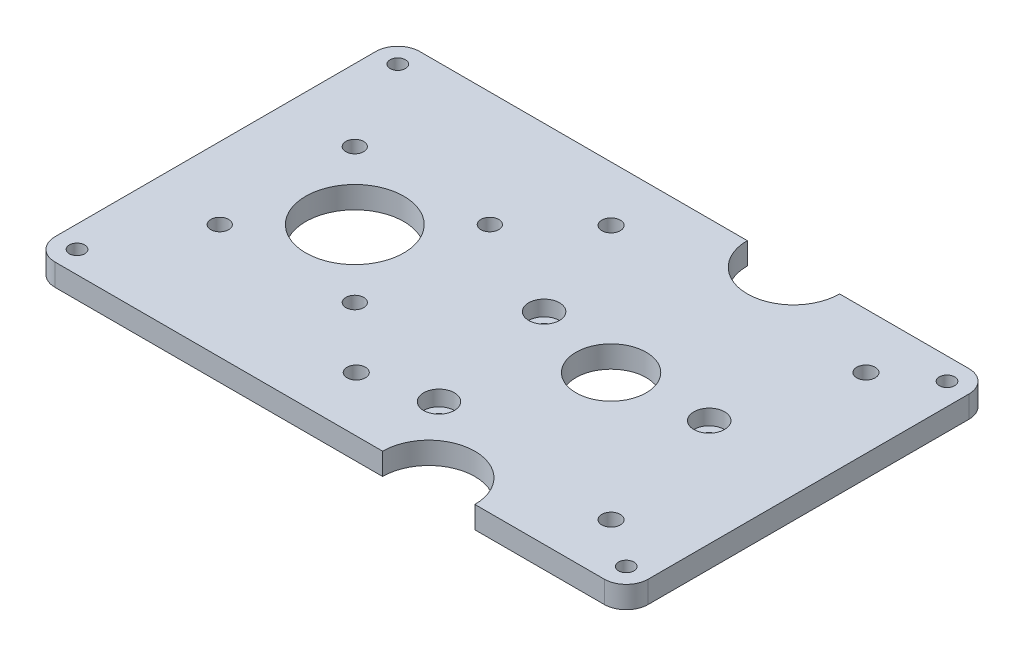
from build123d import *

# Parameters (mm, degrees)
SKETCH1_R           = 2.1
SKETCH1_R_2         = 8
SKETCH1_R_3         = 11.176
SKETCH1_R_4         = 1.75
SKETCH1_R_5         = 2.032
BOSS_EXTRUDE1_DEPTH = 5
FILLET1_R           = 5
SKETCH8_R           = 1.65
CUT_EXTRUDE3_DEPTH  = 10
SKETCH9_R           = 3.5
SKETCH9_R_2         = 1.65
CUT_EXTRUDE4_DEPTH  = 3.5


with BuildPart() as part:
    # Sketch1 → Boss-Extrude1 (new body)
    with BuildSketch(Plane(origin=(0, 0, 0), x_dir=(1, 0, 0), z_dir=(0, 1, 0))):
        with BuildLine():
            Line((67.5, -41.5), (33.05, -41.5))
            ThreePointArc((33.05, -41.5), (22.55, -31), (12.05, -41.5))
            Line((12.05, -41.5), (-67.5, -41.5))
            Line((-67.5, -41.5), (-67.5, 41.5))
            Line((-67.5, 41.5), (12.05, 41.5))
            ThreePointArc((12.05, 41.5), (22.55, 31), (33.05, 41.5))
            Line((33.05, 41.5), (67.5, 41.5))
            Line((67.5, 41.5), (67.5, -41.5))
        make_face()
        with Locations((-6.45, 29)):
            Circle(SKETCH1_R, mode=Mode.SUBTRACT)
        with Locations((51.55, 29)):
            Circle(SKETCH1_R, mode=Mode.SUBTRACT)
        with Locations((51.55, -29)):
            Circle(SKETCH1_R, mode=Mode.SUBTRACT)
        with Locations((-6.45, -29)):
            Circle(SKETCH1_R, mode=Mode.SUBTRACT)
        with Locations((22.55, 0)):
            Circle(SKETCH1_R_2, mode=Mode.SUBTRACT)
        with Locations((-35.78, 0)):
            Circle(SKETCH1_R_3, mode=Mode.SUBTRACT)
        with Locations((-62.5, 36.5)):
            Circle(SKETCH1_R_4, mode=Mode.SUBTRACT)
        with Locations((62.5, 36.5)):
            Circle(SKETCH1_R_4, mode=Mode.SUBTRACT)
        with Locations((62.5, -36.5)):
            Circle(SKETCH1_R_4, mode=Mode.SUBTRACT)
        with Locations((-62.5, -36.5)):
            Circle(SKETCH1_R_4, mode=Mode.SUBTRACT)
        with Locations((-20.413, 15.367)):
            Circle(SKETCH1_R_5, mode=Mode.SUBTRACT)
        with Locations((-20.413, -15.367)):
            Circle(SKETCH1_R_5, mode=Mode.SUBTRACT)
        with Locations((-51.147, -15.367)):
            Circle(SKETCH1_R_5, mode=Mode.SUBTRACT)
        with Locations((-51.147, 15.367)):
            Circle(SKETCH1_R_5, mode=Mode.SUBTRACT)
    extrude(amount=BOSS_EXTRUDE1_DEPTH)

    # Fillet1
    fillet1_edges = [part.edges().sort_by_distance(p)[0] for p in [
        (67.5, 2.5, -41.5),
        (67.5, 2.5, 41.5),
        (-67.5, 2.5, 41.5),
        (-67.5, 2.5, -41.5),
    ]]
    fillet(fillet1_edges, radius=FILLET1_R)

    # Sketch8 → Cut-Extrude3 (cut)
    with BuildSketch(Plane(origin=(0, 5, 0), x_dir=(1, 0, 0), z_dir=(0, 1, 0))):
        with Locations((43.1993197, 1.68214862)):
            Circle(SKETCH8_R)
        with Locations((2.921522344, 4.384015291)):
            Circle(SKETCH8_R)
        with Locations((8.6993197, -25.31785138)):
            Circle(SKETCH8_R)
    extrude(amount=-CUT_EXTRUDE3_DEPTH, mode=Mode.SUBTRACT)

    # Sketch9 → Cut-Extrude4 (cut)
    with BuildSketch(Plane(origin=(0, 5, 0), x_dir=(1, 0, 0), z_dir=(0, 1, 0))):
        with Locations((2.921522344, 4.384015291)):
            Circle(SKETCH9_R)
        with Locations((2.921522344, 4.384015291)):
            Circle(SKETCH9_R_2, mode=Mode.SUBTRACT)
        with Locations((8.6993197, -25.31785138)):
            Circle(SKETCH9_R)
        with Locations((8.6993197, -25.31785138)):
            Circle(SKETCH9_R_2, mode=Mode.SUBTRACT)
        with Locations((43.1993197, 1.68214862)):
            Circle(SKETCH9_R)
        with Locations((43.1993197, 1.68214862)):
            Circle(SKETCH9_R_2, mode=Mode.SUBTRACT)
    extrude(amount=-CUT_EXTRUDE4_DEPTH, mode=Mode.SUBTRACT)


solid = part.part
